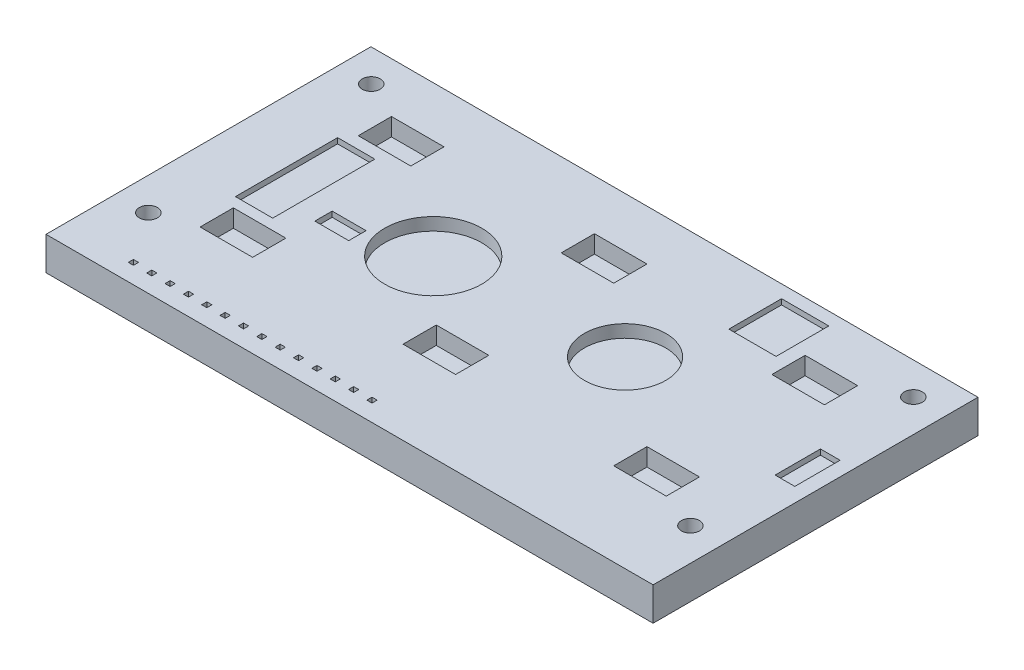
from build123d import *

# Parameters (mm, degrees)
SKETCH1_W           = 84.03
SKETCH1_H           = 44.97
SKETCH1_W_2         = 0.71
SKETCH1_H_2         = 0.71
BOSS_EXTRUDE1_DEPTH = 4.61
CUT_EXTRUDE1_REACH  = 97.418
SKETCH2_R           = 1.25
SKETCH2_3_W         = 7.27
SKETCH2_3_H         = 4.6
CUT_EXTRUDE2_DEPTH  = 2.45
SKETCH2_4_R         = 6.72
SKETCH2_4_R_2       = 5.64
CUT_EXTRUDE3_DEPTH  = 1.75
SKETCH2_5_W         = 6.54
SKETCH2_5_H         = 7.3
SKETCH2_5_W_2       = 2.72
SKETCH2_5_H_2       = 6.27
SKETCH2_5_W_3       = 5.16
SKETCH2_5_H_3       = 14.14
SKETCH2_5_W_4       = 4.69
SKETCH2_5_H_4       = 2.4
CUT_EXTRUDE4_DEPTH  = 0.75


with BuildPart() as part:
    # Sketch1 → Boss-Extrude1 (new body)
    with BuildSketch(Plane(origin=(0, 0, 0), x_dir=(1, 0, 0), z_dir=(0, 1, 0))):
        with Locations((-42.015, -22.485)):
            Rectangle(SKETCH1_W, SKETCH1_H)
        with Locations((-74.615, -42.285)):
            Rectangle(SKETCH1_W_2, SKETCH1_H_2, mode=Mode.SUBTRACT)
        with Locations((-72.075, -42.285)):
            Rectangle(SKETCH1_W_2, SKETCH1_H_2, mode=Mode.SUBTRACT)
        with Locations((-69.535, -42.285)):
            Rectangle(SKETCH1_W_2, SKETCH1_H_2, mode=Mode.SUBTRACT)
        with Locations((-66.995, -42.285)):
            Rectangle(SKETCH1_W_2, SKETCH1_H_2, mode=Mode.SUBTRACT)
        with Locations((-64.455, -42.285)):
            Rectangle(SKETCH1_W_2, SKETCH1_H_2, mode=Mode.SUBTRACT)
        with Locations((-61.915, -42.285)):
            Rectangle(SKETCH1_W_2, SKETCH1_H_2, mode=Mode.SUBTRACT)
        with Locations((-59.375, -42.285)):
            Rectangle(SKETCH1_W_2, SKETCH1_H_2, mode=Mode.SUBTRACT)
        with Locations((-56.835, -42.285)):
            Rectangle(SKETCH1_W_2, SKETCH1_H_2, mode=Mode.SUBTRACT)
        with Locations((-54.295, -42.285)):
            Rectangle(SKETCH1_W_2, SKETCH1_H_2, mode=Mode.SUBTRACT)
        with Locations((-51.755, -42.285)):
            Rectangle(SKETCH1_W_2, SKETCH1_H_2, mode=Mode.SUBTRACT)
        with Locations((-49.215, -42.285)):
            Rectangle(SKETCH1_W_2, SKETCH1_H_2, mode=Mode.SUBTRACT)
        with Locations((-46.675, -42.285)):
            Rectangle(SKETCH1_W_2, SKETCH1_H_2, mode=Mode.SUBTRACT)
        with Locations((-44.135, -42.285)):
            Rectangle(SKETCH1_W_2, SKETCH1_H_2, mode=Mode.SUBTRACT)
        with Locations((-41.595, -42.285)):
            Rectangle(SKETCH1_W_2, SKETCH1_H_2, mode=Mode.SUBTRACT)
    extrude(amount=BOSS_EXTRUDE1_DEPTH)

    # Sketch2 → Cut-Extrude1 (cut, up to next)
    with BuildSketch(Plane(origin=(0, 4.61, 0), x_dir=(1, 0, 0), z_dir=(0, 1, 0)), mode=Mode.PRIVATE) as cut_extrude1_sk1:
        with Locations((-79.535, -4.45)):
            Circle(SKETCH2_R)
    cut_extrude1_tool1 = extrude(cut_extrude1_sk1.sketch, amount=-CUT_EXTRUDE1_REACH, mode=Mode.PRIVATE) & part.part
    # Sketch2 → Cut-Extrude1 (cut, up to next)
    with BuildSketch(Plane(origin=(0, 4.61, 0), x_dir=(1, 0, 0), z_dir=(0, 1, 0)), mode=Mode.PRIVATE) as cut_extrude1_sk2:
        with Locations((-79.535, -35.3)):
            Circle(SKETCH2_R)
    cut_extrude1_tool2 = extrude(cut_extrude1_sk2.sketch, amount=-CUT_EXTRUDE1_REACH, mode=Mode.PRIVATE) & part.part
    # Sketch2 → Cut-Extrude1 (cut, up to next)
    with BuildSketch(Plane(origin=(0, 4.61, 0), x_dir=(1, 0, 0), z_dir=(0, 1, 0)), mode=Mode.PRIVATE) as cut_extrude1_sk3:
        with Locations((-4.5, -4.45)):
            Circle(SKETCH2_R)
    cut_extrude1_tool3 = extrude(cut_extrude1_sk3.sketch, amount=-CUT_EXTRUDE1_REACH, mode=Mode.PRIVATE) & part.part
    # Sketch2 → Cut-Extrude1 (cut, up to next)
    with BuildSketch(Plane(origin=(0, 4.61, 0), x_dir=(1, 0, 0), z_dir=(0, 1, 0)), mode=Mode.PRIVATE) as cut_extrude1_sk4:
        with Locations((-4.5, -35.3)):
            Circle(SKETCH2_R)
    cut_extrude1_tool4 = extrude(cut_extrude1_sk4.sketch, amount=-CUT_EXTRUDE1_REACH, mode=Mode.PRIVATE) & part.part
    add(cut_extrude1_tool1.solids().sort_by_distance((-79.535, 4.61, 4.45))[0], mode=Mode.SUBTRACT)
    add(cut_extrude1_tool2.solids().sort_by_distance((-79.535, 4.61, 35.3))[0], mode=Mode.SUBTRACT)
    add(cut_extrude1_tool3.solids().sort_by_distance((-4.5, 4.61, 4.45))[0], mode=Mode.SUBTRACT)
    add(cut_extrude1_tool4.solids().sort_by_distance((-4.5, 4.61, 35.3))[0], mode=Mode.SUBTRACT)

    # Sketch2_3 → Cut-Extrude2 (cut)
    with BuildSketch(Plane(origin=(0, 4.61, 0), x_dir=(1, 0, 0), z_dir=(0, 1, 0))):
        with Locations((-13.355, -9.24)):
            Rectangle(SKETCH2_3_W, SKETCH2_3_H)
        with Locations((-42.515, -9.24)):
            Rectangle(SKETCH2_3_W, SKETCH2_3_H)
        with Locations((-70.605, -9.24)):
            Rectangle(SKETCH2_3_W, SKETCH2_3_H)
        with Locations((-70.605, -31.13)):
            Rectangle(SKETCH2_3_W, SKETCH2_3_H)
        with Locations((-42.515, -31.13)):
            Rectangle(SKETCH2_3_W, SKETCH2_3_H)
        with Locations((-13.355, -31.13)):
            Rectangle(SKETCH2_3_W, SKETCH2_3_H)
    extrude(amount=-CUT_EXTRUDE2_DEPTH, mode=Mode.SUBTRACT)

    # Sketch2_4 → Cut-Extrude3 (cut)
    with BuildSketch(Plane(origin=(0, 4.61, 0), x_dir=(1, 0, 0), z_dir=(0, 1, 0))):
        with Locations((-54.61, -20.79)):
            Circle(SKETCH2_4_R)
        with Locations((-29.26, -19.59)):
            Circle(SKETCH2_4_R_2)
    extrude(amount=-CUT_EXTRUDE3_DEPTH, mode=Mode.SUBTRACT)

    # Sketch2_5 → Cut-Extrude4 (cut)
    with BuildSketch(Plane(origin=(0, 4.61, 0), x_dir=(1, 0, 0), z_dir=(0, 1, 0))):
        with Locations((-22.14, -5.43)):
            Rectangle(SKETCH2_5_W, SKETCH2_5_H)
        with Locations((-3.35, -20.235)):
            Rectangle(SKETCH2_5_W_2, SKETCH2_5_H_2)
        with Locations((-72.86, -20.27)):
            Rectangle(SKETCH2_5_W_3, SKETCH2_5_H_3)
        with Locations((-64.665, -23.58)):
            Rectangle(SKETCH2_5_W_4, SKETCH2_5_H_4)
    extrude(amount=-CUT_EXTRUDE4_DEPTH, mode=Mode.SUBTRACT)


solid = part.part
